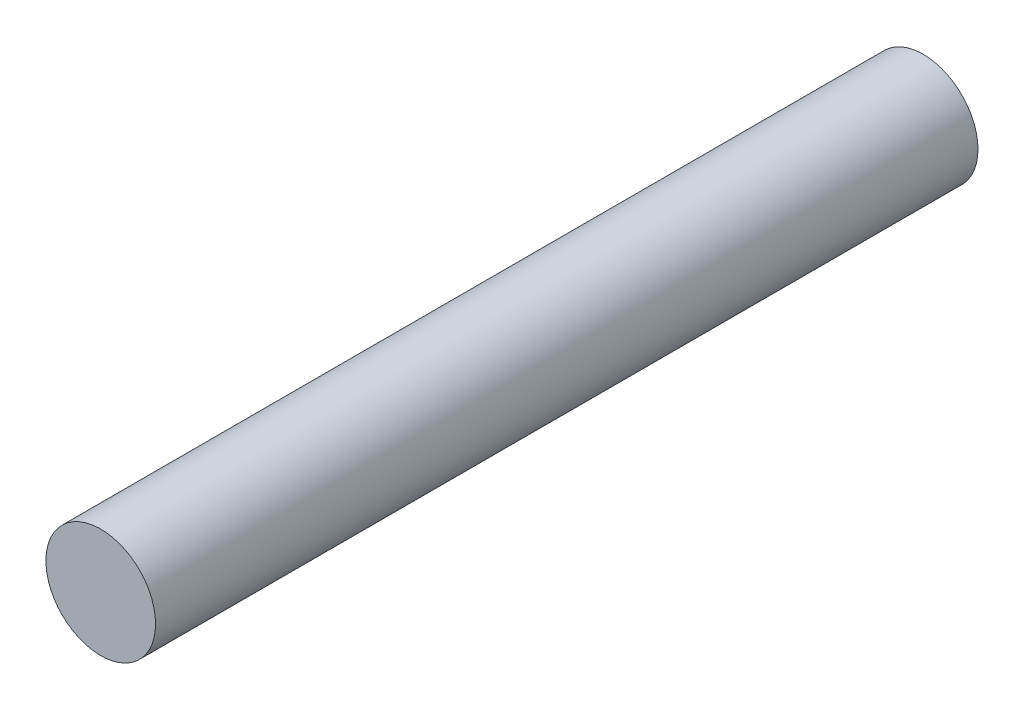
from build123d import *

# Parameters (mm, degrees)
CROQUIS1_R              = 4
SALIENTE_EXTRUIR1_DEPTH = 60


with BuildPart() as part:
    # Croquis1 → Saliente-Extruir1 (new body)
    with BuildSketch(Plane.XY):
        Circle(CROQUIS1_R)
    extrude(amount=SALIENTE_EXTRUIR1_DEPTH)


solid = part.part
